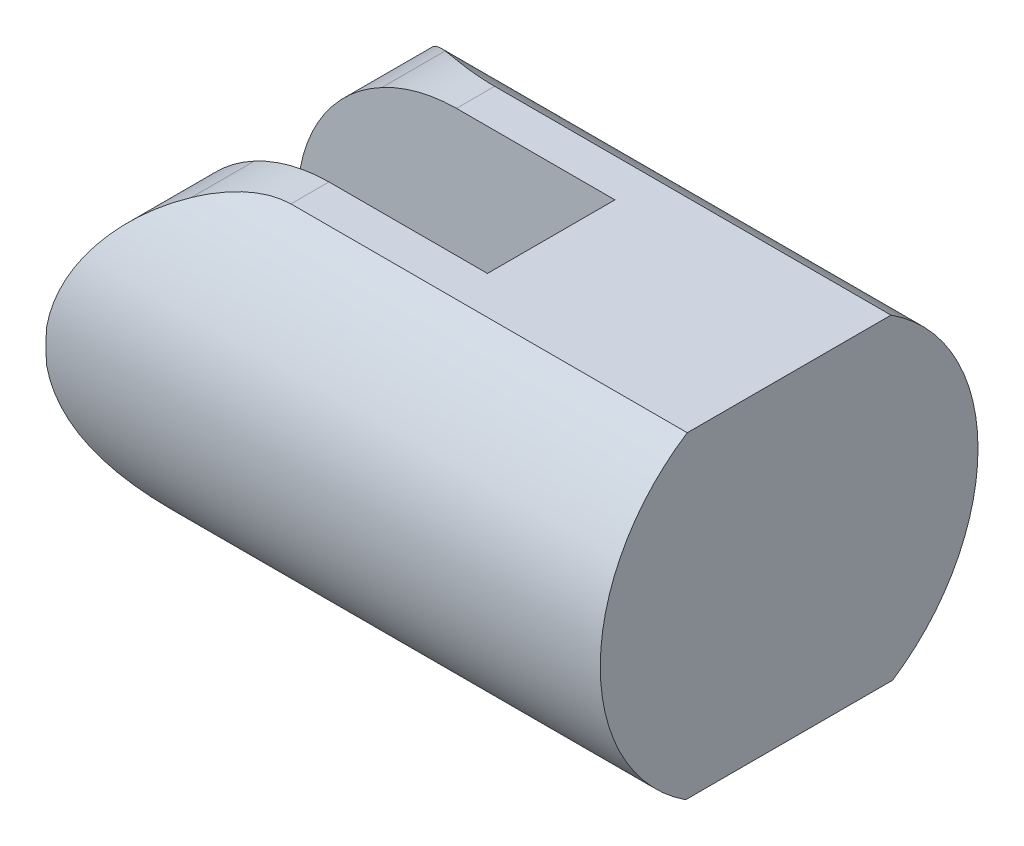
from build123d import *

# Parameters (mm, degrees)
BOSS_EXTRUDE1_DEPTH = 13.5
SKETCH2_W           = 5.4
SKETCH2_H           = 14
CUT_EXTRUDE1_DEPTH  = 13.5
SKETCH3_R           = 12.152813435
SKETCH3_R_2         = 8
CUT_EXTRUDE2_DEPTH  = 24.574911634
BOSS_EXTRUDE2_DEPTH = 32.5
CUT_EXTRUDE4_DEPTH  = 25.746559571
SKETCH8_W           = 15.715396091
SKETCH8_H           = 5.4
CUT_EXTRUDE5_DEPTH  = 23.5


with BuildPart() as part:
    # Sketch1 → Boss-Extrude1 (new body)
    with BuildSketch(Plane.XY):
        with BuildLine():
            Line((-6.75, 0.697518811), (-6.75, -0.720756429))
            ThreePointArc((-6.75, -0.720756429), (-5.635274328, -3.766828408), (-3.219489146, -5.931349089))
            Line((-3.219489146, -5.931349089), (16.824911634, -5.931349089))
            Line((16.824911634, -5.931349089), (16.824911634, 5.931349089))
            Line((16.824911634, 5.931349089), (-3.175088366, 5.931349089))
            ThreePointArc((-3.175088366, 5.931349089), (-5.621180267, 3.764308263), (-6.75, 0.697518811))
        make_face()
    extrude(amount=BOSS_EXTRUDE1_DEPTH)

    # Sketch2 → Cut-Extrude1 (cut)
    with BuildSketch(Plane.ZY.offset(6.75)):
        with Locations((6.75, 0)):
            Rectangle(SKETCH2_W, SKETCH2_H)
    extrude(amount=-CUT_EXTRUDE1_DEPTH, mode=Mode.SUBTRACT)

    # Sketch3 → Cut-Extrude2 (cut, through all)
    with BuildSketch(Plane(origin=(16.824911634, 0, 0), x_dir=(0, 0, -1), z_dir=(1, 0, 0))):
        with Locations((-6.746559471, 0)):
            Circle(SKETCH3_R)
        with Locations((-6.746559471, 0)):
            Circle(SKETCH3_R_2, mode=Mode.SUBTRACT)
    extrude(amount=-CUT_EXTRUDE2_DEPTH, mode=Mode.SUBTRACT)

    # Sketch4 → Boss-Extrude2 (add)
    with BuildSketch(Plane(origin=(16.824911634, 0, 0), x_dir=(0, 0, -1), z_dir=(1, 0, 0))):
        with BuildLine():
            Line((-1.37821727, -5.931349089), (-12.114901672, -5.931349089))
            ThreePointArc((-12.114901672, -5.931349089), (-6.746559471, -8), (-1.37821727, -5.931349089))
        make_face()
        with BuildLine():
            Line((-13.5, -4.288477704), (-13.5, 4.288477704))
            ThreePointArc((-13.5, 4.288477704), (-14.746559471, 0), (-13.5, -4.288477704))
        make_face()
        with BuildLine():
            ThreePointArc((-1.37821727, 5.931349089), (-6.746559471, 8), (-12.114901672, 5.931349089))
            Line((-12.114901672, 5.931349089), (-1.37821727, 5.931349089))
        make_face()
        with BuildLine():
            ThreePointArc((1.253440529, 0), (0.933690387, 2.239143166), (0, 4.299294745))
            Line((0, 4.299294745), (0, -4.299294745))
            ThreePointArc((0, -4.299294745), (0.933690387, -2.239143166), (1.253440529, 0))
        make_face()
    extrude(amount=-BOSS_EXTRUDE2_DEPTH)

    # Sketch7 → Cut-Extrude4 (cut, through all)
    with BuildSketch(Plane.XY.offset(-10)):
        with BuildLine():
            Line((-6.656945588, -0.70913762), (-6.656945588, 0.70913762))
            ThreePointArc((-6.656945588, 0.70913762), (-6.164537152, 2.610801109), (-5.141365169, 4.287675936))
            ThreePointArc((-5.141365169, 4.287675936), (-4.213671695, 5.202189114), (-3.126434734, 5.91973028))
            ThreePointArc((-3.126434734, 5.91973028), (-1.594815167, 6.522683652), (0.037211277, 6.736928732))
            Line((0.037211277, 6.736928732), (17.631347577, 6.736928732))
            Line((17.631347577, 6.736928732), (17.631347577, 9.936708938))
            Line((17.631347577, 9.936708938), (-17.152869805, 9.936708938))
            Line((-17.152869805, 9.936708938), (-17.769305726, -9.133185925))
            Line((-17.769305726, -9.133185925), (18.753818668, -9.133185925))
            Line((18.753818668, -9.133185925), (18.753818668, -6.692966124))
            Line((18.753818668, -6.692966124), (0.148341476, -6.692966124))
            ThreePointArc((0.148341476, -6.692966124), (-1.514021871, -6.521160825), (-3.082033954, -5.942967898))
            ThreePointArc((-3.082033954, -5.942967898), (-4.182346183, -5.227406732), (-5.121896627, -4.310913554))
            ThreePointArc((-5.121896627, -4.310913554), (-6.158610107, -2.62475185), (-6.656945588, -0.70913762))
        make_face()
    extrude(amount=CUT_EXTRUDE4_DEPTH, mode=Mode.SUBTRACT)

    # Sketch8 → Cut-Extrude5 (cut)
    with BuildSketch(Plane.XZ.offset(6.692966124)):
        with Locations((-1.107698046, 6.75)):
            Rectangle(SKETCH8_W, SKETCH8_H)
    extrude(amount=-CUT_EXTRUDE5_DEPTH, mode=Mode.SUBTRACT)


solid = part.part
